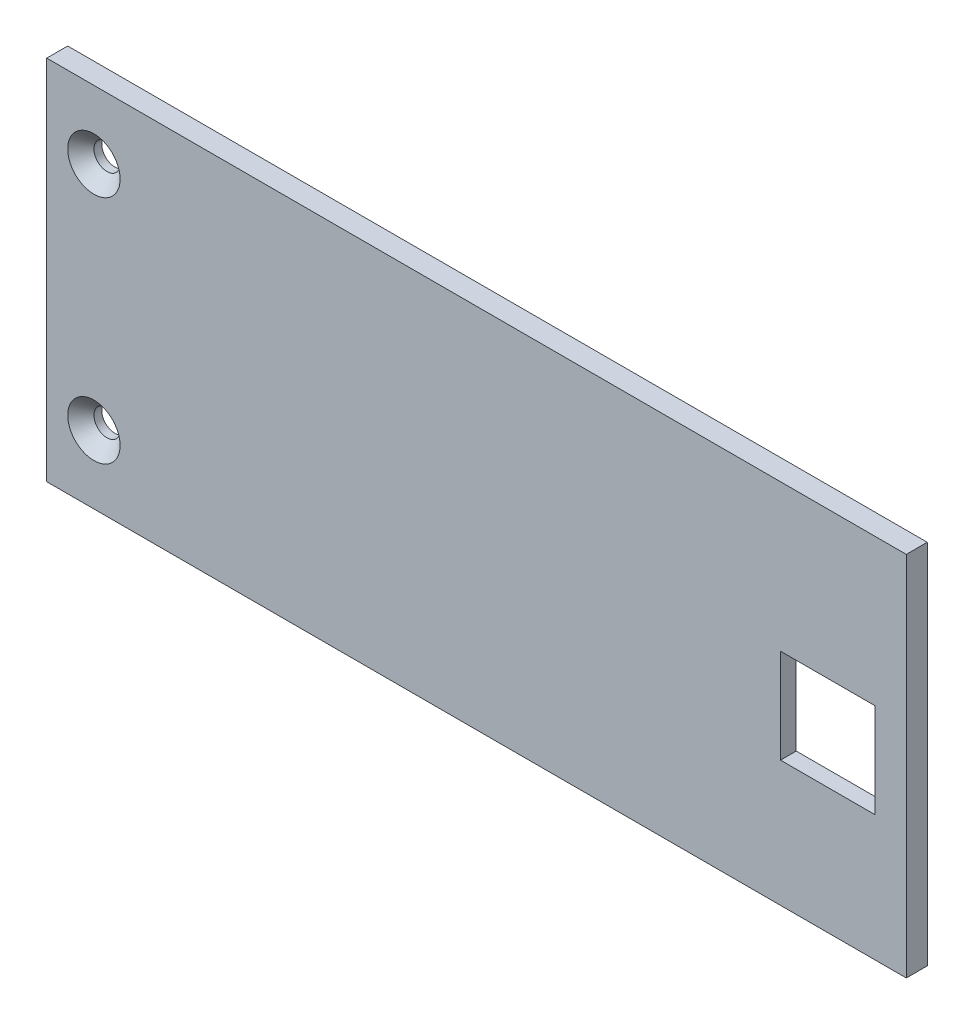
from build123d import *

# Parameters (mm, degrees)
ESQUISSE1_W             = 82
ESQUISSE1_H             = 35
ESQUISSE1_R             = 1.25
EXTRUSION1_DEPTH        = 2
CHANFREIN1_SIZE         = 1.25
ESQUISSE2_W             = 10
ESQUISSE2_H             = 10
ENL_V_MAT_EXTRU_1_DEPTH = 0.5


with BuildPart() as part:
    # Esquisse1 → Extrusion1 (new body)
    with BuildSketch(Plane.XY):
        with Locations((-41, 17.5)):
            Rectangle(ESQUISSE1_W, ESQUISSE1_H)
        with Locations((-77.5, 28.5)):
            Circle(ESQUISSE1_R, mode=Mode.SUBTRACT)
        with Locations((-77.5, 6.5)):
            Circle(ESQUISSE1_R, mode=Mode.SUBTRACT)
        Polygon((-12, 21), (-3, 21), (-3, 12), (-12, 12), (-12, 16.5), align=None, mode=Mode.SUBTRACT)
    extrude(amount=EXTRUSION1_DEPTH)

    # Chanfrein1
    chanfrein1_edges = [part.edges().sort_by_distance(p)[0] for p in [
        (-78.75, 28.5, 2),
        (-78.75, 6.5, 2),
    ]]
    chamfer(chanfrein1_edges, length=CHANFREIN1_SIZE)

    # Esquisse2 → Enlèv. mat.-Extru.1 (cut)
    with BuildSketch(Plane(origin=(0, 0, 0), x_dir=(-1, 0, 0), z_dir=(0, 0, -1))):
        with Locations((7.5, 16.5)):
            Rectangle(ESQUISSE2_W, ESQUISSE2_H)
    extrude(amount=-ENL_V_MAT_EXTRU_1_DEPTH, mode=Mode.SUBTRACT)


solid = part.part
